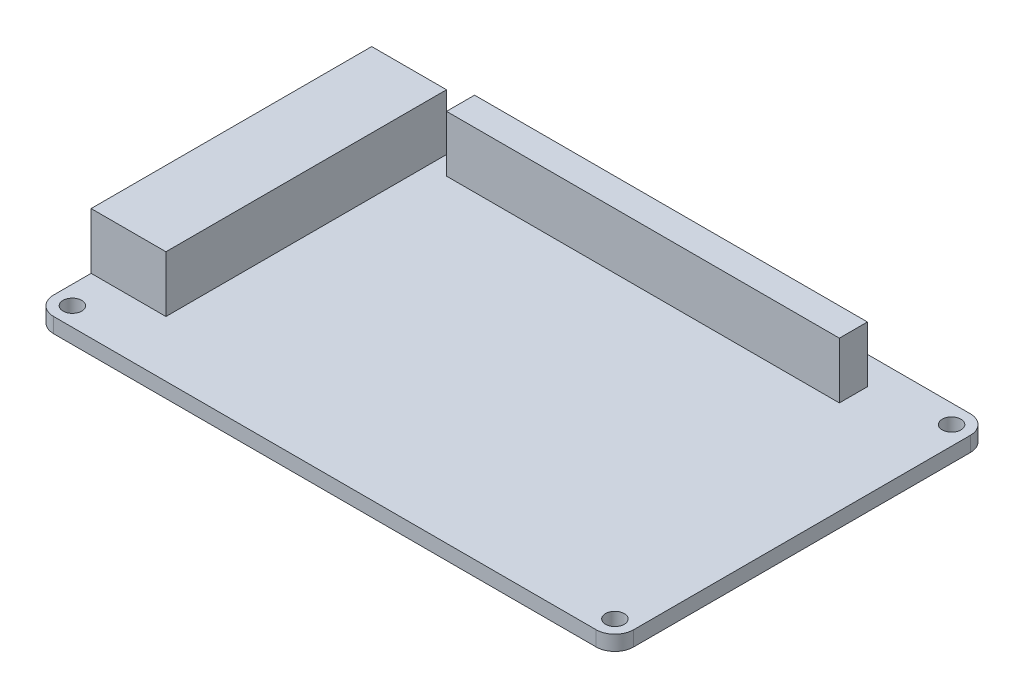
from build123d import *

# Parameters (mm, degrees)
SKETCH1_R                    = 1.5875
MAINPCB_DEPTH                = 2.54
SKETCH2_W                    = 12.7
SKETCH2_H                    = 47.625
CHARGER_USBCONNECTIONS_DEPTH = 9.525
SKETCH3_W                    = 66.675
SKETCH3_H                    = 4.7625
GPIO_HEADER_DEPTH            = 9.525


with BuildPart() as part:
    # Sketch1 → MainPCB (new body)
    with BuildSketch(Plane(origin=(0, 0, 0), x_dir=(1, 0, 0), z_dir=(0, 1, 0))):
        with BuildLine():
            Line((-46.0375, 31.75), (46.0375, 31.75))
            ThreePointArc((46.0375, 31.75), (48.28256403, 30.82006403), (49.2125, 28.575))
            Line((49.2125, 28.575), (49.2125, -28.575))
            ThreePointArc((49.2125, -28.575), (48.28256403, -30.82006403), (46.0375, -31.75))
            Line((46.0375, -31.75), (-46.0375, -31.75))
            ThreePointArc((-46.0375, -31.75), (-48.28256403, -30.82006403), (-49.2125, -28.575))
            Line((-49.2125, -28.575), (-49.2125, 28.575))
            ThreePointArc((-49.2125, 28.575), (-48.28256403, 30.82006403), (-46.0375, 31.75))
        make_face()
        with Locations((-46.0375, 28.575)):
            Circle(SKETCH1_R, mode=Mode.SUBTRACT)
        with Locations((46.0375, 28.575)):
            Circle(SKETCH1_R, mode=Mode.SUBTRACT)
        with Locations((46.0375, -28.575)):
            Circle(SKETCH1_R, mode=Mode.SUBTRACT)
        with Locations((-46.0375, -28.575)):
            Circle(SKETCH1_R, mode=Mode.SUBTRACT)
    extrude(amount=MAINPCB_DEPTH)

    # Sketch2 → Charger_USBConnections (add)
    with BuildSketch(Plane(origin=(0, 2.54, 0), x_dir=(1, 0, 0), z_dir=(0, 1, 0))):
        with Locations((-42.8625, 1.5875)):
            Rectangle(SKETCH2_W, SKETCH2_H)
    extrude(amount=CHARGER_USBCONNECTIONS_DEPTH)

    # Sketch3 → GPIO Header (add)
    with BuildSketch(Plane(origin=(0, 2.54, 0), x_dir=(1, 0, 0), z_dir=(0, 1, 0))):
        with Locations((0, 24.60625)):
            Rectangle(SKETCH3_W, SKETCH3_H)
    extrude(amount=GPIO_HEADER_DEPTH)


solid = part.part
